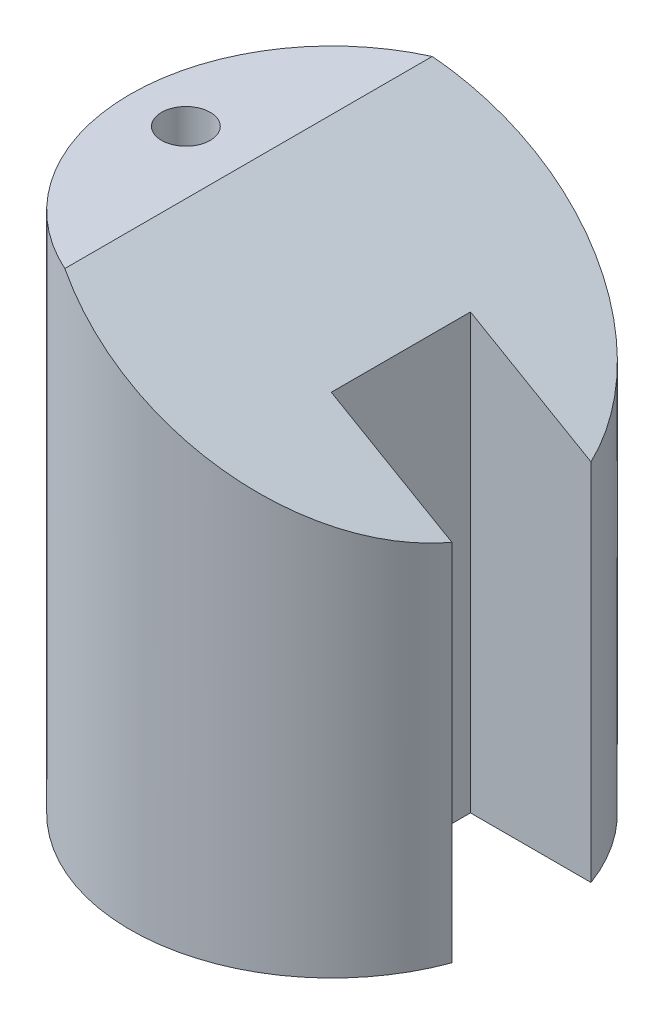
from build123d import *

# Parameters (mm, degrees)
SKETCH1_R               = 29
BOSS_EXTRUDE1_DEPTH     = 75
SKETCH3_R               = 3.5
BOSS_EXTRUDE3_DEPTH     = 50
SKETCH3_4_R             = 3.5
CUT_EXTRUDE1_DEPTH      = 50
CUT_EXTRUDE2_DEPTH      = 86.480992039
CUT_EXTRUDE2_DEPTH_BACK = 86.480992039
CUT_EXTRUDE4_DEPTH      = 96.841219197


with BuildPart() as part:
    # Sketch1 → Boss-Extrude1 (new body)
    with BuildSketch(Plane(origin=(0, 0, 0), x_dir=(1, 0, 0), z_dir=(0, 1, 0))):
        Circle(SKETCH1_R)
    extrude(amount=BOSS_EXTRUDE1_DEPTH)

    # Sketch3 → Boss-Extrude3 (add)
    with BuildSketch(Plane(origin=(0, 75, 0), x_dir=(1, 0, 0), z_dir=(0, 1, 0))):
        with Locations((-21, 0)):
            Circle(SKETCH3_R)
    extrude(amount=-BOSS_EXTRUDE3_DEPTH)

    # Sketch3_4 → Cut-Extrude1 (cut)
    with BuildSketch(Plane(origin=(0, 75, 0), x_dir=(1, 0, 0), z_dir=(0, 1, 0))):
        with Locations((-21, 0)):
            Circle(SKETCH3_4_R)
    extrude(amount=-CUT_EXTRUDE1_DEPTH, mode=Mode.SUBTRACT)

    # Sketch9 → Cut-Extrude2 (cut, two sides: drawn at the far end of the back side and taken through both)
    with BuildSketch(Plane.XY.offset(-CUT_EXTRUDE2_DEPTH_BACK)):
        Polygon((-12, 75), (29, 75), (29, 51.328638963), align=None)
    extrude(amount=CUT_EXTRUDE2_DEPTH + CUT_EXTRUDE2_DEPTH_BACK, mode=Mode.SUBTRACT)

    # Sketch18 → Cut-Extrude4 (cut, through all, along a direction that is not the sketch's normal)
    with BuildSketch(Plane(origin=(29.475952642, 51.053847577, 0), x_dir=(0.866025403784438, -0.5000000000000012, 0), z_dir=(0.5000000000000011, 0.8660254037844379, 0))):
        with BuildLine():
            Line((-2.603431094, 10), (-22.603431094, 10))
            Line((-22.603431094, 10), (-22.603431094, -10))
            Line((-22.603431094, -10), (-2.603431094, -10))
            add(Edge.make_bspline(
                [(-2.603431094, -10), (1.638467326, 0), (-2.603431094, 10)],
                knots=[5.931130208, 5.931130208, 5.931130208, 6.635240406, 6.635240406, 6.635240406], degree=2, weights=[1, 0.938666041, 1]))
        make_face()
    extrude(amount=-CUT_EXTRUDE4_DEPTH, dir=(0, 1, 0), mode=Mode.SUBTRACT)


solid = part.part
